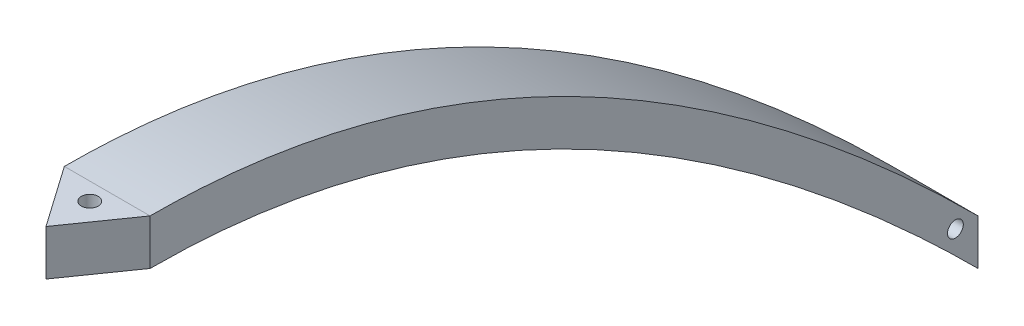
from build123d import *

# Parameters (mm, degrees)
BOSS_EXTRUDE1_DEPTH = 10.52068
BOSS_EXTRUDE3_DEPTH = 5.588
SKETCH4_R           = 1.037113256
CUT_EXTRUDE1_DEPTH  = 5.588
SKETCH5_R           = 0.970454713
CUT_EXTRUDE2_DEPTH  = 10.52068


with BuildPart() as part:
    # Sketch1 → Boss-Extrude1 (new body)
    with BuildSketch(Plane(origin=(0, 0, 0), x_dir=(0, 0, -1), z_dir=(1, 0, 0))):
        with BuildLine():
            Line((0, 0), (0, 5.588000005))
            add(Edge.make_bspline(
                [(0, 5.588000005), (50.799999991, 5.588000023), (101.6, -45.211999941)],
                knots=[0.084768036, 0.084768036, 0.084768036, 0.932448396, 0.932448396, 0.932448396], degree=2))
            Line((101.6, -45.211999941), (101.6, -50.799999941))
            add(Edge.make_bspline(
                [(0, 0), (50.79999999, 2e-08), (101.6, -50.799999941)],
                knots=[0.084768036, 0.084768036, 0.084768036, 0.932448396, 0.932448396, 0.932448396], degree=2))
        make_face()
    extrude(amount=BOSS_EXTRUDE1_DEPTH)

    # Sketch2 → Boss-Extrude3 (add)
    with BuildSketch(Plane(origin=(0, 0, 0), x_dir=(1, 0, 0), z_dir=(0, 1, 0))):
        Polygon((0, 0), (10.52068, 0), (5.26034, -7.512544086), align=None)
    extrude(amount=BOSS_EXTRUDE3_DEPTH)

    # Sketch4 → Cut-Extrude1 (cut)
    with BuildSketch(Plane(origin=(0, 5.588000005, 0), x_dir=(1, 0, 0), z_dir=(0, 1, 0))):
        with Locations((5.26034, -2.137251975)):
            Circle(SKETCH4_R)
    extrude(amount=-CUT_EXTRUDE1_DEPTH, mode=Mode.SUBTRACT)

    # Sketch5 → Cut-Extrude2 (cut)
    with BuildSketch(Plane.ZY):
        with Locations((-98.825997746, -45.21199994)):
            Circle(SKETCH5_R)
    extrude(amount=-CUT_EXTRUDE2_DEPTH, mode=Mode.SUBTRACT)


solid = part.part
